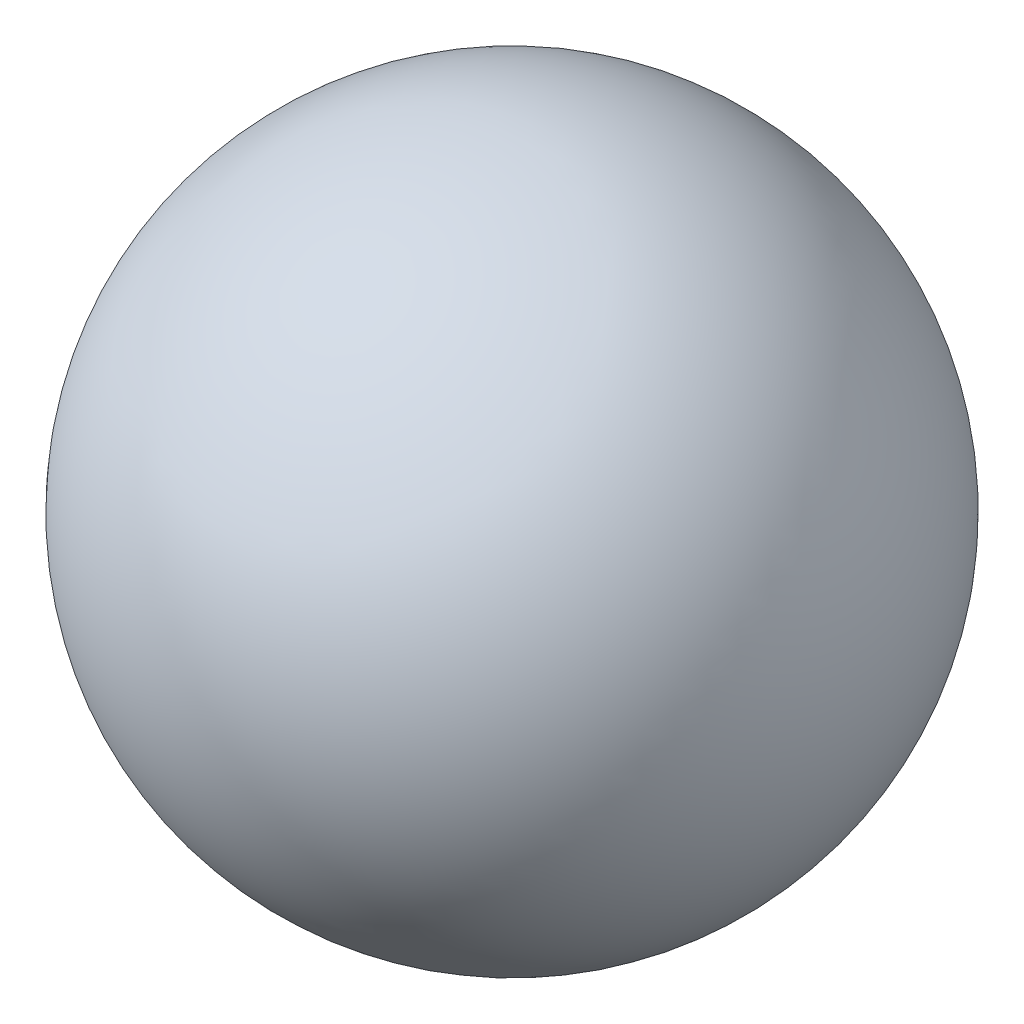
from build123d import *


with BuildPart() as part:
    # Sketch2 one side → Revolve4 (revolve)
    with BuildSketch(Plane(origin=(0, 0, 0), x_dir=(1, 0, 0), z_dir=(0, 1, 0))):
        with BuildLine():
            ThreePointArc((-24.965607258, -19.615834274), (10.377968722, -30.006003819), (31.75, 0))
            ThreePointArc((31.75, 0), (30.006003819, 10.377968722), (24.965607258, 19.615834274))
            Line((24.965607258, 19.615834274), (-24.965607258, -19.615834274))
        make_face()
    revolve(axis=Axis((0, 0, 0), (-0.786318339, 0, 0.617821552)))


solid = part.part
